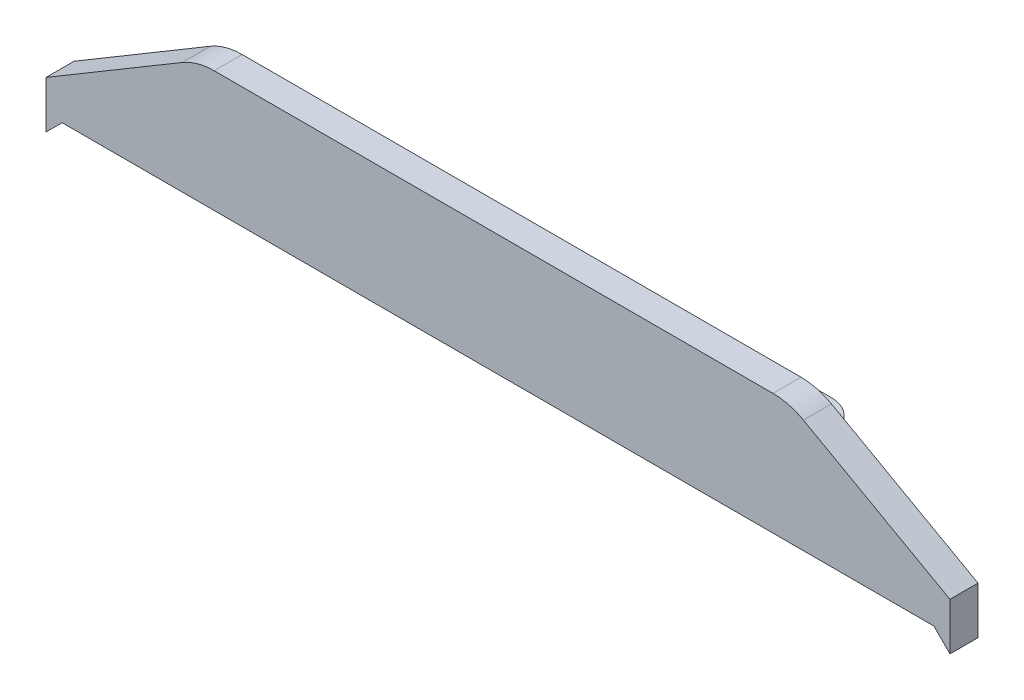
from build123d import *

# Parameters (mm, degrees)
BOSS_EXTRUDE1_DEPTH = 4.5
SKETCH2_R           = 1.65
BOSS_EXTRUDE2_DEPTH = 3
FILLET1_R           = 10


with BuildPart() as part:
    # Sketch1 → Boss-Extrude1 (new body)
    with BuildSketch(Plane.XY):
        Polygon((145, -50.8), (119.218266921, -36.385786438), (24.218266921, -36.385786438), (0, -50.8), (0, -58.385786438), (2.585786438, -55.8), (142.414213562, -55.8), (145, -58.385786438), align=None)
    extrude(amount=BOSS_EXTRUDE1_DEPTH)

    # Sketch2 → Boss-Extrude2 (add)
    with BuildSketch(Plane(origin=(0, -53.8, 0), x_dir=(1, 0, 0), z_dir=(0, 1, 0))):
        with BuildLine():
            Line((123.505440237, 0), (110.90639088, 12.599049358))
            ThreePointArc((110.90639088, 12.599049358), (109.349158805, 13.639558564), (107.51227833, 14.004936808))
            Line((107.51227833, 14.004936808), (37.48772167, 14.004936808))
            ThreePointArc((37.48772167, 14.004936808), (35.650841195, 13.639558564), (34.09360912, 12.599049358))
            Line((34.09360912, 12.599049358), (21.494559763, 0))
            Line((21.494559763, 0), (123.505440237, 0))
        make_face()
        with Locations((37.48772167, 9.204936808)):
            Circle(SKETCH2_R, mode=Mode.SUBTRACT)
        with Locations((107.51227833, 9.204936808)):
            Circle(SKETCH2_R, mode=Mode.SUBTRACT)
    extrude(amount=BOSS_EXTRUDE2_DEPTH)

    # Fillet1
    fillet1_edges = [part.edges().sort_by_distance(p)[0] for p in [
        (119.218266921, -36.385786438, 2.25),
        (24.218266921, -36.385786438, 2.25),
    ]]
    fillet(fillet1_edges, radius=FILLET1_R)


solid = part.part
